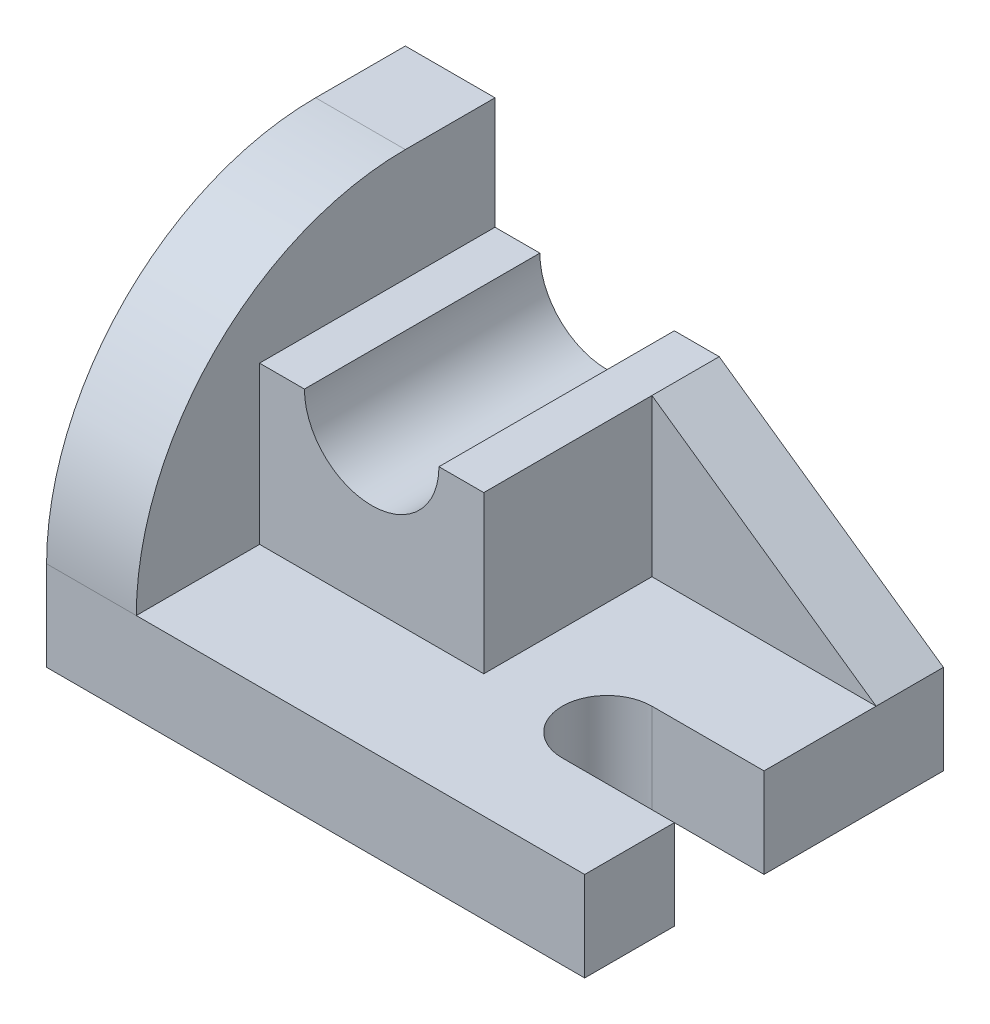
from build123d import *

# Parameters (mm, degrees)
SKETCH1_W           = 96
SKETCH1_H           = 64
BOSS_EXTRUDE1_DEPTH = 16
CUT_EXTRUDE1_DEPTH  = 16
BOSS_EXTRUDE2_DEPTH = 16
SKETCH4_W           = 40
SKETCH4_H           = 42
BOSS_EXTRUDE3_DEPTH = 28
CUT_EXTRUDE2_START  = -42
SKETCH5_R           = 12
CUT_EXTRUDE2_DEPTH  = 42
BOSS_EXTRUDE4_DEPTH = 12


with BuildPart() as part:
    # Sketch1 → Boss-Extrude1 (new body)
    with BuildSketch(Plane(origin=(0, 0, 0), x_dir=(1, 0, 0), z_dir=(0, 1, 0))):
        with Locations((48, 32)):
            Rectangle(SKETCH1_W, SKETCH1_H)
    extrude(amount=BOSS_EXTRUDE1_DEPTH)

    # Sketch2 → Cut-Extrude1 (cut)
    with BuildSketch(Plane(origin=(0, 16, 0), x_dir=(1, 0, 0), z_dir=(0, 1, 0))):
        with BuildLine():
            Line((96, 16), (76, 16))
            ThreePointArc((76, 16), (68, 24), (76, 32))
            Line((76, 32), (96, 32))
            ThreePointArc((96, 32), (104, 24), (96, 16))
        make_face()
    extrude(amount=-CUT_EXTRUDE1_DEPTH, mode=Mode.SUBTRACT)

    # Sketch3 → Boss-Extrude2 (add)
    with BuildSketch(Plane.ZY):
        with BuildLine():
            Line((-64, 0), (0, 0))
            Line((0, 0), (0, 16))
            ThreePointArc((0, 16), (-14.058874503, 49.941125497), (-48, 64))
            Line((-48, 64), (-64, 64))
            Line((-64, 64), (-64, 0))
        make_face()
    extrude(amount=-BOSS_EXTRUDE2_DEPTH)

    # Sketch4 → Boss-Extrude3 (add)
    with BuildSketch(Plane(origin=(0, 16, 0), x_dir=(1, 0, 0), z_dir=(0, 1, 0))):
        with Locations((36, 43)):
            Rectangle(SKETCH4_W, SKETCH4_H)
    extrude(amount=BOSS_EXTRUDE3_DEPTH)

    # Sketch5 → Cut-Extrude2 (cut)
    with BuildSketch(Plane.XY.offset(-22).offset(CUT_EXTRUDE2_START)):
        with Locations((36, 44)):
            Circle(SKETCH5_R)
    extrude(amount=CUT_EXTRUDE2_DEPTH, mode=Mode.SUBTRACT)

    # Sketch8 → Boss-Extrude4 (add)
    with BuildSketch(Plane(origin=(0, 0, -64), x_dir=(-1, 0, 0), z_dir=(0, 0, -1))):
        Polygon((-56, 44), (-96, 16), (-56, 16), align=None)
    extrude(amount=-BOSS_EXTRUDE4_DEPTH)


solid = part.part
